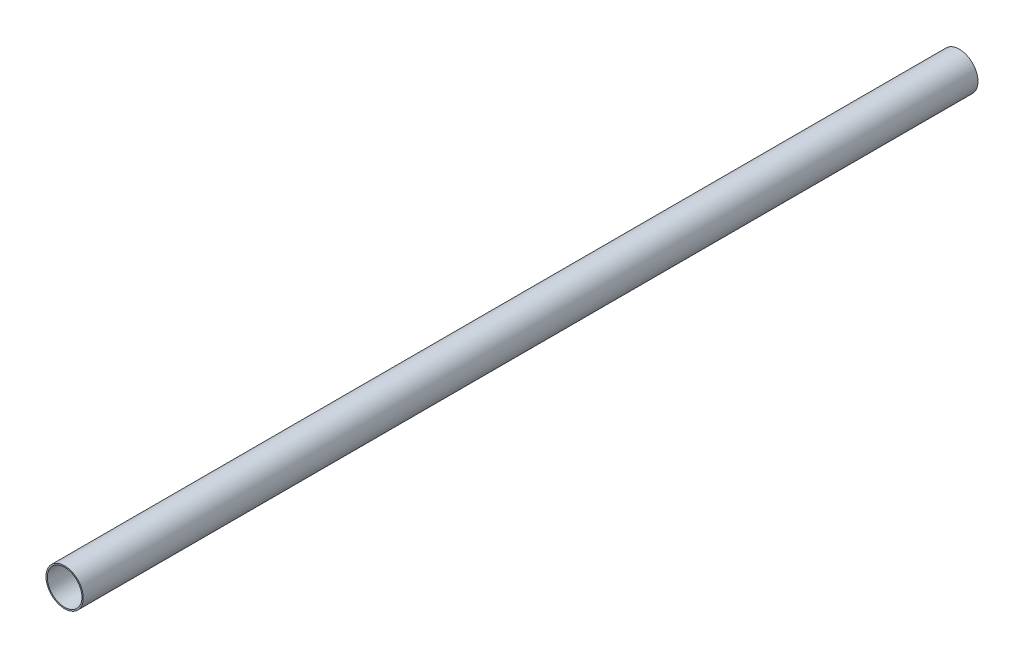
from build123d import *

# Parameters (mm, degrees)
SKETCH1_R           = 6.35
SKETCH1_R_2         = 5.9055
BOSS_EXTRUDE1_DEPTH = 304.8


with BuildPart() as part:
    # Sketch1 → Boss-Extrude1 (new body)
    with BuildSketch(Plane.XY):
        Circle(SKETCH1_R)
        Circle(SKETCH1_R_2, mode=Mode.SUBTRACT)
    extrude(amount=BOSS_EXTRUDE1_DEPTH)


solid = part.part
